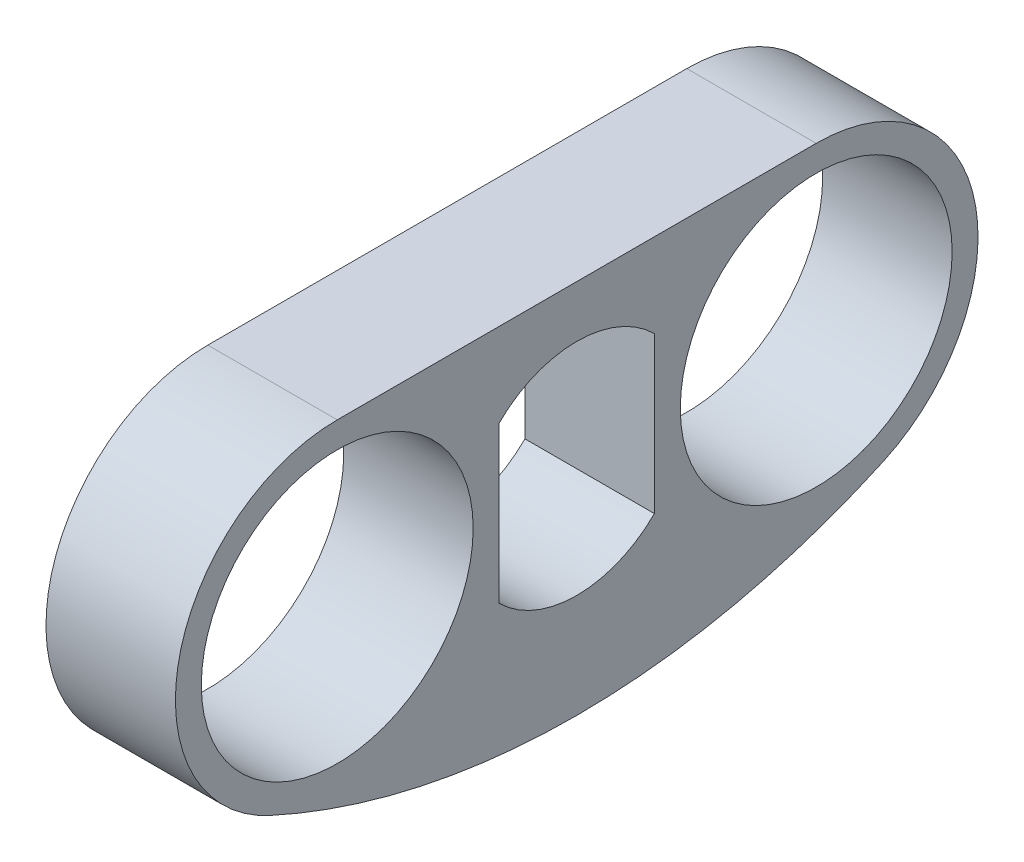
from build123d import *

# Parameters (mm, degrees)
CROQUIS1_R              = 10.5
SALIENTE_EXTRUIR1_DEPTH = 10


with BuildPart() as part:
    # Croquis1 → Saliente-Extruir1 (new body)
    with BuildSketch(Plane(origin=(0, 0, 0), x_dir=(0, 0, -1), z_dir=(1, 0, 0))):
        with BuildLine():
            Line((-18.5, 12.5), (18.5, 12.5))
            ThreePointArc((18.5, 12.5), (30.713875068, 2.659183298), (23.696629213, -11.36859907))
            ThreePointArc((23.696629213, -11.36859907), (0, -16.52778731), (-23.696629213, -11.36859907))
            ThreePointArc((-23.696629213, -11.36859907), (-30.713875068, 2.659183298), (-18.5, 12.5))
        make_face()
        with Locations((18.5, 0)):
            Circle(CROQUIS1_R, mode=Mode.SUBTRACT)
        with Locations((-18.5, 0)):
            Circle(CROQUIS1_R, mode=Mode.SUBTRACT)
        with BuildLine():
            Line((-6, -6.020797289), (-6, 6.020797289))
            ThreePointArc((-6, 6.020797289), (0, 8.5), (6, 6.020797289))
            Line((6, 6.020797289), (6, -6.020797289))
            ThreePointArc((6, -6.020797289), (0, -8.5), (-6, -6.020797289))
        make_face(mode=Mode.SUBTRACT)
    extrude(amount=SALIENTE_EXTRUIR1_DEPTH)


solid = part.part
